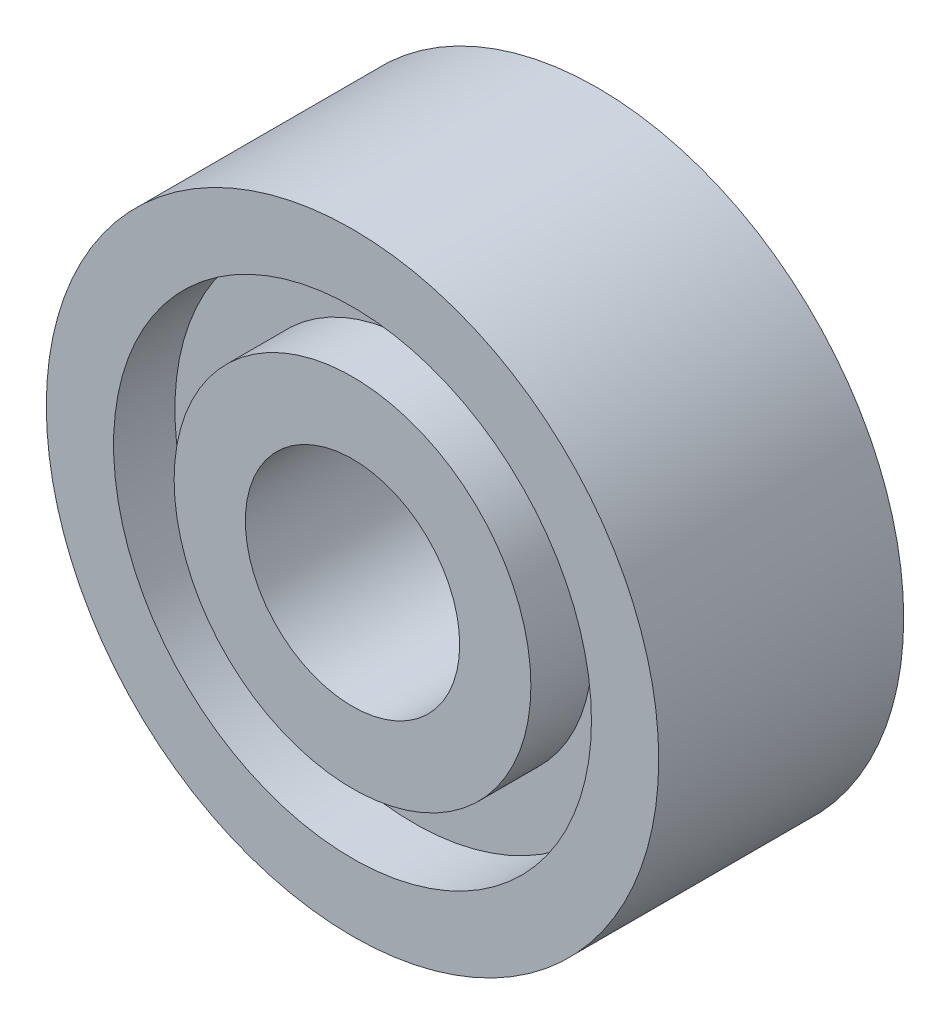
from build123d import *


with BuildPart() as part:
    # Эскиз2 → Повернуть1 (revolve)
    with BuildSketch(Plane(origin=(0, 0, 0), x_dir=(0, 0, -1), z_dir=(1, 0, 0))):
        Polygon((0, 10), (8, 10), (8, 7.80314821), (6.432371813, 7.80314821), (6.432371813, 5.825414178), (8, 5.825414178), (8, 3.5), (0, 3.5), (0, 5.825414178), (2.002247581, 5.825414178), (2.002247581, 7.80314821), (0, 7.80314821), align=None)
    revolve(axis=Axis((0, 0, 23.314285714), (0, 0, -1)))


solid = part.part
